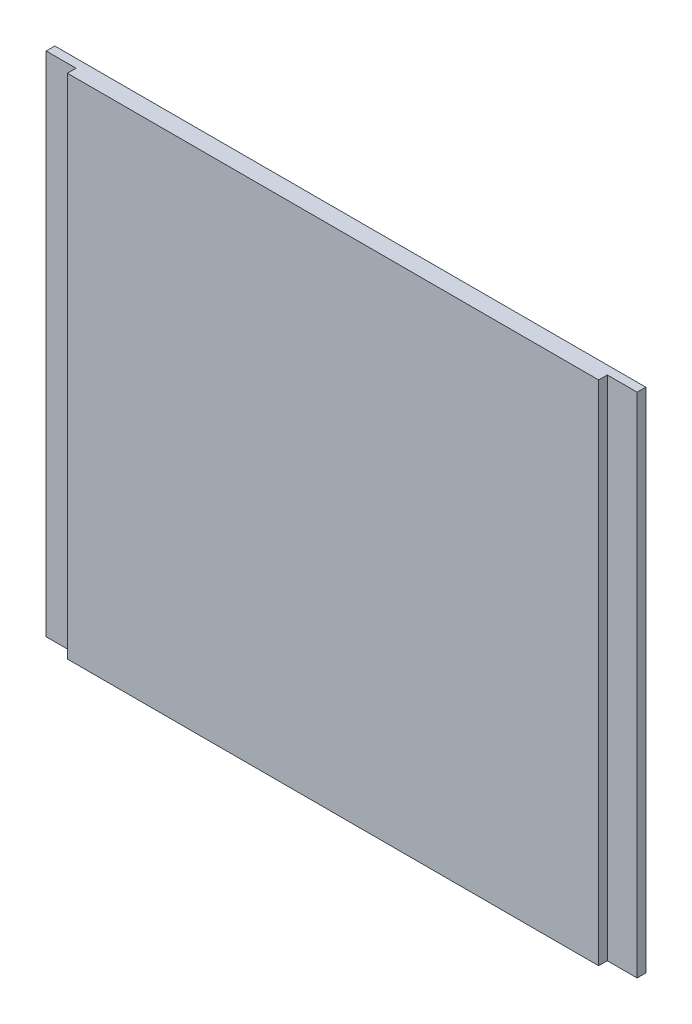
from build123d import *

# Parameters (mm, degrees)
BOSS_EXTRUDE1_DEPTH = 85


with BuildPart() as part:
    # Sketch2 → Boss-Extrude1 (new body)
    with BuildSketch(Plane(origin=(0, 0, 0), x_dir=(1, 0, 0), z_dir=(0, 1, 0))):
        Polygon((-54.31372549, 1.45), (44.68627451, 1.45), (44.68627451, 0), (39.68627451, 0), (39.68627451, -1.45), (-49.31372549, -1.45), (-49.31372549, 0), (-54.31372549, 0), align=None)
    extrude(amount=BOSS_EXTRUDE1_DEPTH)


solid = part.part
